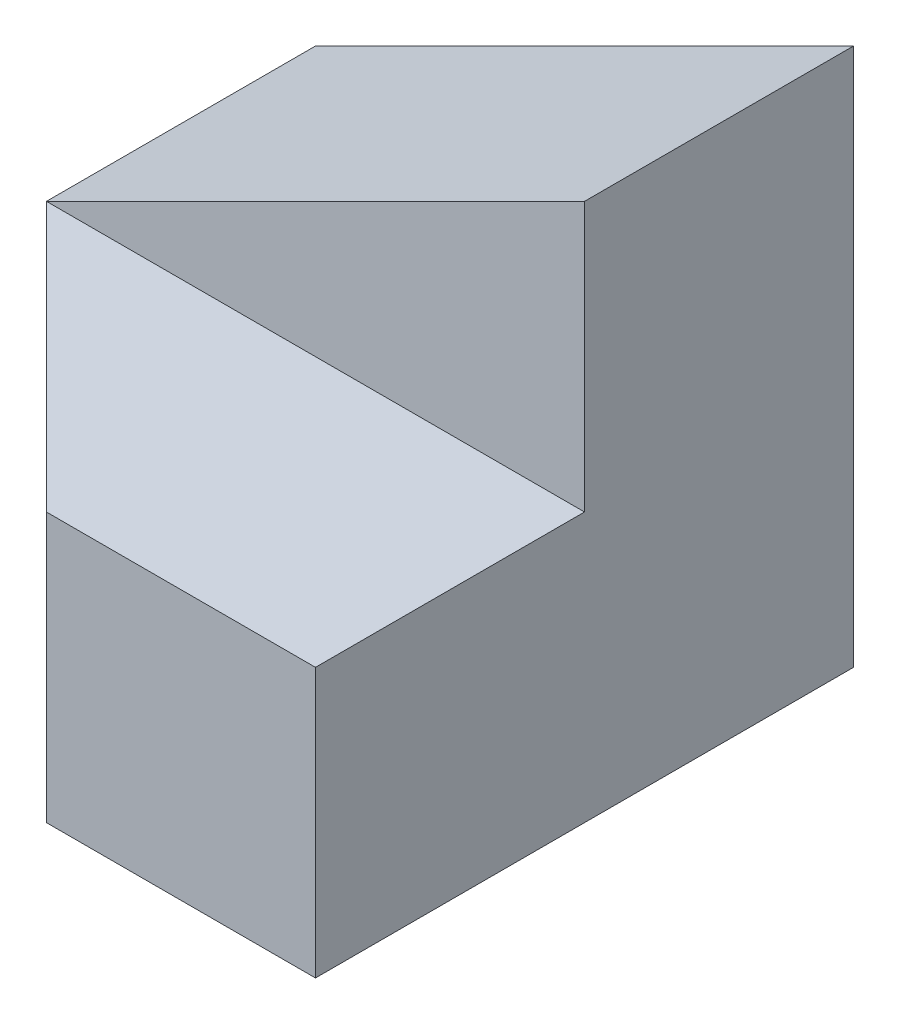
from build123d import *

# Parameters (mm, degrees)
SKETCH1_W           = 40
SKETCH1_H           = 40
BOSS_EXTRUDE1_DEPTH = 40
CUT_EXTRUDE1_DEPTH  = 40
SKETCH3_W           = 20
SKETCH3_H           = 20
CUT_EXTRUDE2_DEPTH  = 40
CUT_EXTRUDE3_DEPTH  = 40


with BuildPart() as part:
    # Sketch1 → Boss-Extrude1 (new body)
    with BuildSketch(Plane.XY):
        with Locations((20, 20)):
            Rectangle(SKETCH1_W, SKETCH1_H)
    extrude(amount=BOSS_EXTRUDE1_DEPTH)

    # Sketch2 → Cut-Extrude1 (cut)
    with BuildSketch(Plane.XY.offset(40)):
        Polygon((40, 40), (0, 20), (0, 40), align=None)
    extrude(amount=-CUT_EXTRUDE1_DEPTH, mode=Mode.SUBTRACT)

    # Sketch3 → Cut-Extrude2 (cut)
    with BuildSketch(Plane(origin=(40, 0, 0), x_dir=(0, 0, -1), z_dir=(1, 0, 0))):
        with Locations((-30, 30)):
            Rectangle(SKETCH3_W, SKETCH3_H)
    extrude(amount=-CUT_EXTRUDE2_DEPTH, mode=Mode.SUBTRACT)

    # Sketch4 → Cut-Extrude3 (cut)
    with BuildSketch(Plane(origin=(0, 20, 0), x_dir=(1, 0, 0), z_dir=(0, 1, 0))):
        Polygon((0, -20), (20, -40), (0, -40), align=None)
    extrude(amount=-CUT_EXTRUDE3_DEPTH, mode=Mode.SUBTRACT)


solid = part.part
